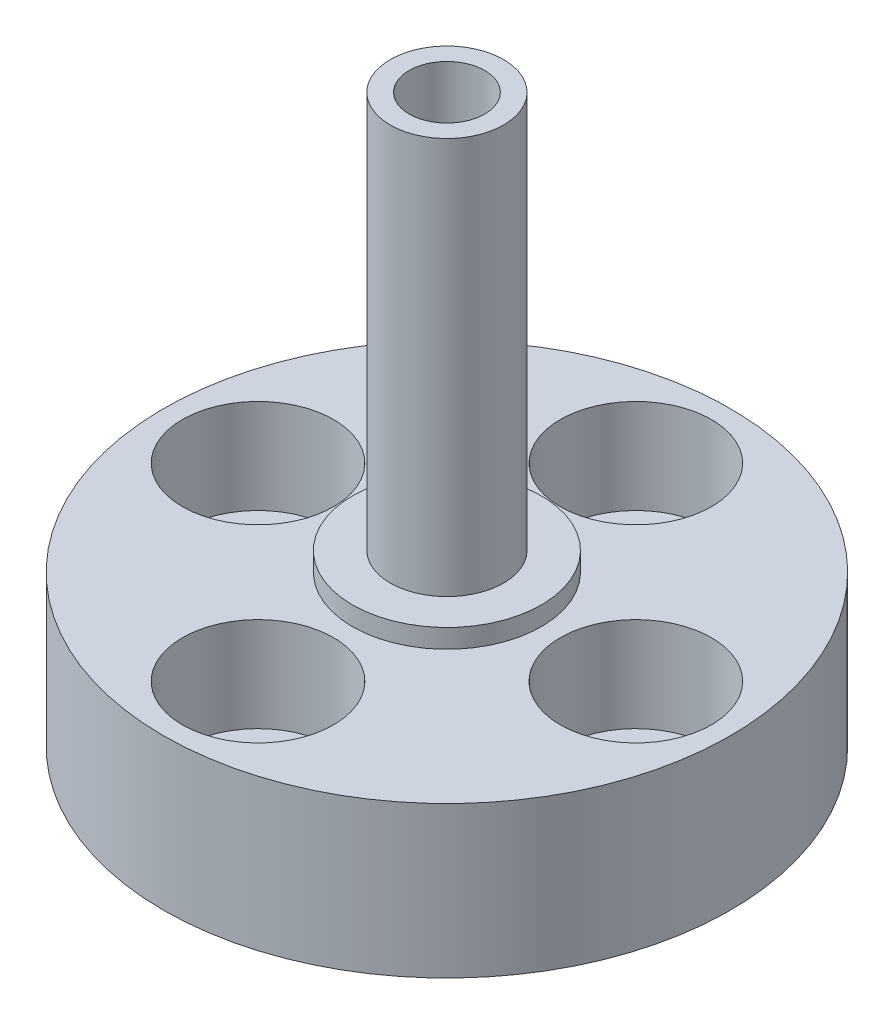
from build123d import *

# Parameters (mm, degrees)
SKETCH1_R           = 15
BOSS_EXTRUDE1_DEPTH = 8
SKETCH2_R           = 5
BOSS_EXTRUDE2_DEPTH = 1
SKETCH3_R           = 3
BOSS_EXTRUDE3_DEPTH = 21
HOLE1_D             = 4
HOLE1_CBORE_D       = 8
HOLE1_CBORE_DEPTH   = 5
SKETCH8_R           = 2
CUT_EXTRUDE1_DEPTH  = 12


with BuildPart() as part:
    # Sketch1 → Boss-Extrude1 (new body)
    with BuildSketch(Plane(origin=(0, 0, 0), x_dir=(1, 0, 0), z_dir=(0, 1, 0))):
        Circle(SKETCH1_R)
    extrude(amount=BOSS_EXTRUDE1_DEPTH)

    # Sketch2 → Boss-Extrude2 (add)
    with BuildSketch(Plane(origin=(0, 8, 0), x_dir=(1, 0, 0), z_dir=(0, 1, 0))):
        Circle(SKETCH2_R)
    extrude(amount=BOSS_EXTRUDE2_DEPTH)

    # Sketch3 → Boss-Extrude3 (add)
    with BuildSketch(Plane(origin=(0, 9, 0), x_dir=(1, 0, 0), z_dir=(0, 1, 0))):
        Circle(SKETCH3_R)
    extrude(amount=BOSS_EXTRUDE3_DEPTH)

    # Hole1 (through all)
    with Locations(Plane(origin=(0, 8, 0), x_dir=(1, 0, 0), z_dir=(0, 1, 0))):
        with Locations((-10, 0), (0, 10), (10, 0), (0, -10)):
            CounterBoreHole(HOLE1_D / 2, HOLE1_CBORE_D / 2, HOLE1_CBORE_DEPTH)

    # Sketch8 → Cut-Extrude1 (cut)
    with BuildSketch(Plane(origin=(0, 30, 0), x_dir=(1, 0, 0), z_dir=(0, 1, 0))):
        Circle(SKETCH8_R)
    extrude(amount=-CUT_EXTRUDE1_DEPTH, mode=Mode.SUBTRACT)


solid = part.part
